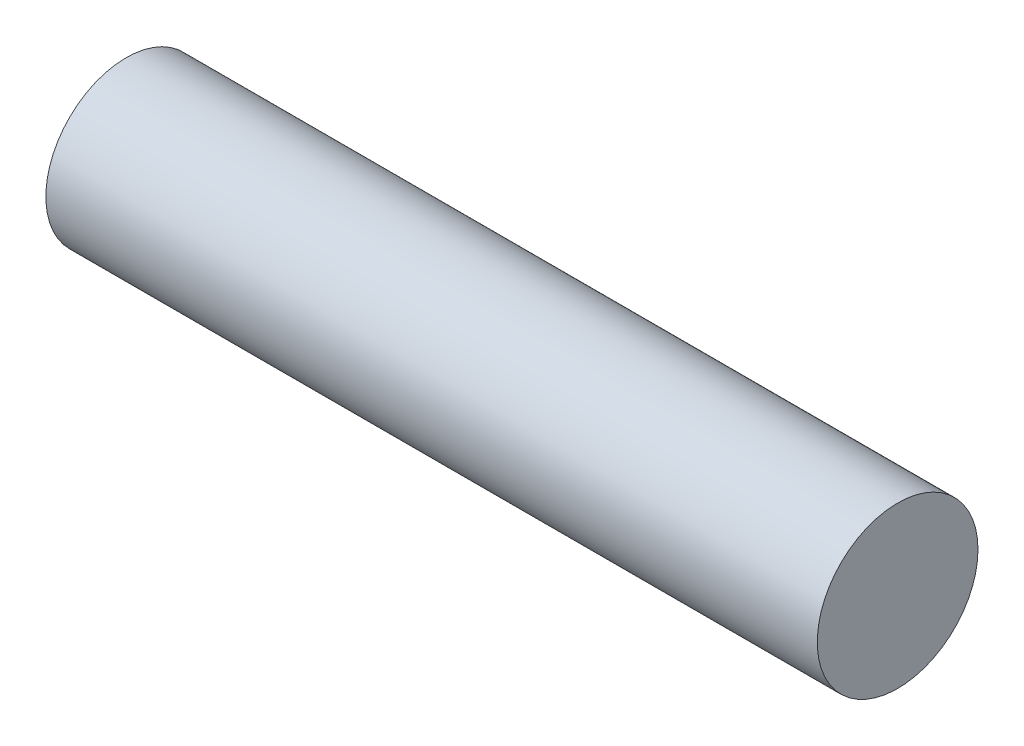
from build123d import *

# Parameters (mm, degrees)
SKETCH2_R           = 3.96875
EXTRUDE1_DEPTH      = 19.05
EXTRUDE1_DEPTH_BACK = 19.05


with BuildPart() as part:
    # Sketch2 → Extrude1 (new body, two sides)
    with BuildSketch(Plane(origin=(0, 0, 0), x_dir=(0, 0, -1), z_dir=(1, 0, 0))) as extrude1_sk:
        Circle(SKETCH2_R)
    extrude(amount=EXTRUDE1_DEPTH)
    extrude(extrude1_sk.sketch, amount=-EXTRUDE1_DEPTH_BACK)


solid = part.part
